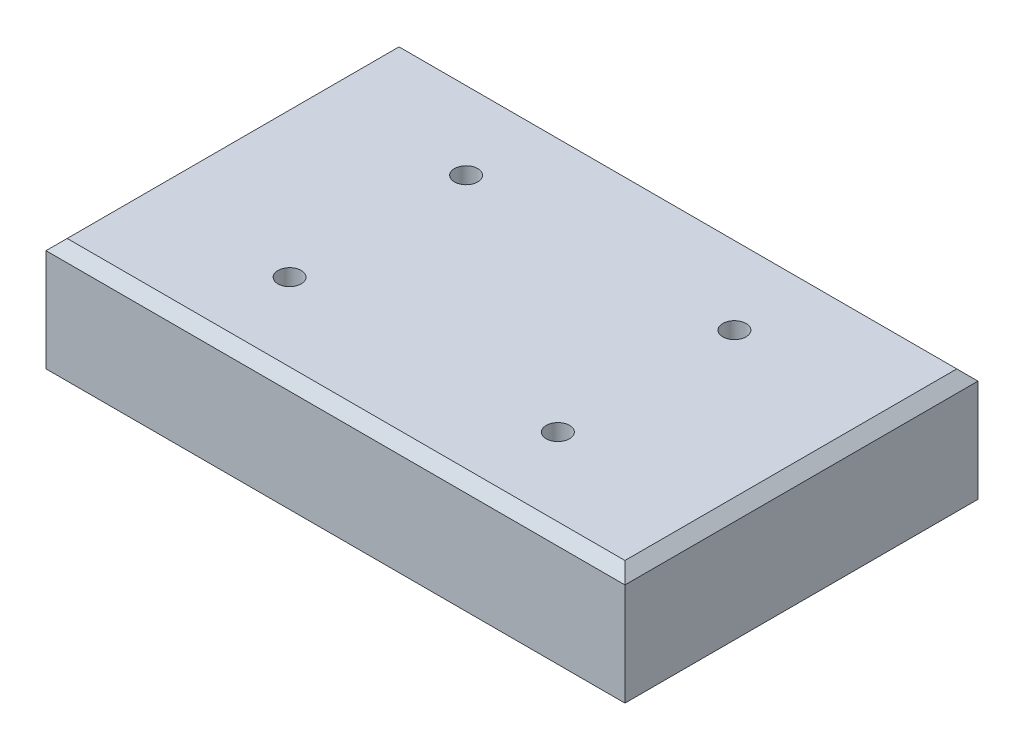
from build123d import *

# Parameters (mm, degrees)
SKETCH1_W             = 82
SKETCH1_H             = 50
BOSS_EXTRUDE1_DEPTH   = 16
CHAMFER1_SIZE         = 1.5
M4_TAPPED_HOLE1_D     = 3.3
M4_TAPPED_HOLE1_DEPTH = 6
M4_TAPPED_HOLE1_TIP   = 0.991420021


with BuildPart() as part:
    # Sketch1 → Boss-Extrude1 (new body)
    with BuildSketch(Plane(origin=(0, 0, 0), x_dir=(1, 0, 0), z_dir=(0, 1, 0))):
        Rectangle(SKETCH1_W, SKETCH1_H)
    extrude(amount=BOSS_EXTRUDE1_DEPTH)

    # Chamfer1
    chamfer1_edges = [part.edges().sort_by_distance(p)[0] for p in [
        (41, 16, 0),
        (0, 16, -25),
        (-41, 16, 0),
        (0, 16, 25),
    ]]
    chamfer(chamfer1_edges, length=CHAMFER1_SIZE)

    # M4 Tapped Hole1
    with Locations(Plane(origin=(0, 16, 0), x_dir=(1, 0, 0), z_dir=(0, 1, 0))):
        with Locations((-19, 12.5), (19, 12.5), (19, -12.5), (-19, -12.5)):
            Hole(M4_TAPPED_HOLE1_D / 2, depth=M4_TAPPED_HOLE1_DEPTH)
            with Locations((0, 0, -(M4_TAPPED_HOLE1_DEPTH + M4_TAPPED_HOLE1_TIP / 2))):  # 118° drill point
                Cone(0, M4_TAPPED_HOLE1_D / 2, M4_TAPPED_HOLE1_TIP, mode=Mode.SUBTRACT)


solid = part.part
